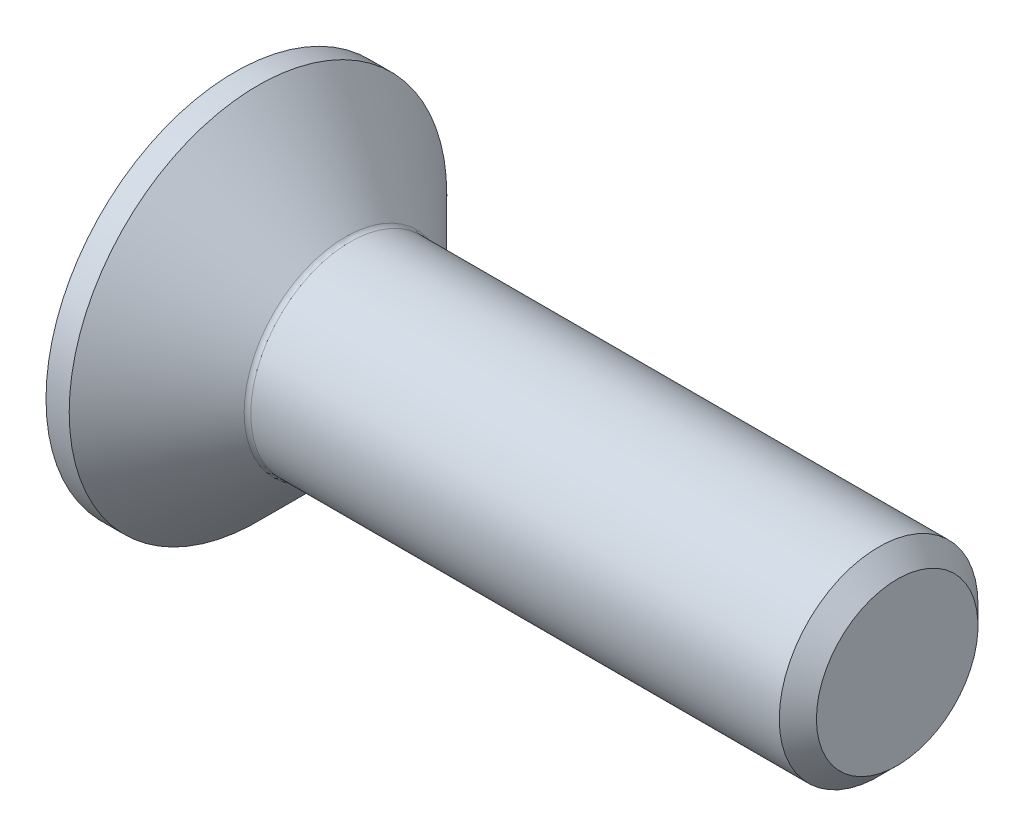
from build123d import *

# Parameters (mm, degrees)
FILLET1_R   = 0.1
HEX_2_DEPTH = 1.2


with BuildPart() as part:
    # BodySke → BaseBody (revolve)
    with BuildSketch(Plane.XY):
        Polygon((0, 0), (0, 2.85), (0.35, 2.85), (1.7, 1.5), (9.7195, 1.5), (10, 1.2195), (10, 0), align=None)
    revolve(axis=Axis((0, 0, 0), (1, 0, 0)))

    # Fillet1
    fillet1_edges = [part.edges().sort_by_distance(p)[0] for p in [
        (1.7, -1.5, 0),
    ]]
    fillet(fillet1_edges, radius=FILLET1_R)

    # Sketch2 → PreBroach (revolve, cut)
    with BuildSketch(Plane.XY):
        Polygon((0, 1.01), (1.2, 1.01), (1.783123772, 0), (0, 0), align=None)
    revolve(axis=Axis((0, 0, 0), (1, 0, 0)), mode=Mode.SUBTRACT)

    # Sketch3 → Hex 2 (cut)
    with BuildSketch(Plane.ZY):
        Polygon((-1.01, -0.583123772), (-1.01, 0.583123772), (0, 1.166247544), (1.01, 0.583123772), (1.01, -0.583123772), (0, -1.166247544), align=None)
    extrude(amount=-HEX_2_DEPTH, mode=Mode.SUBTRACT)


solid = part.part
